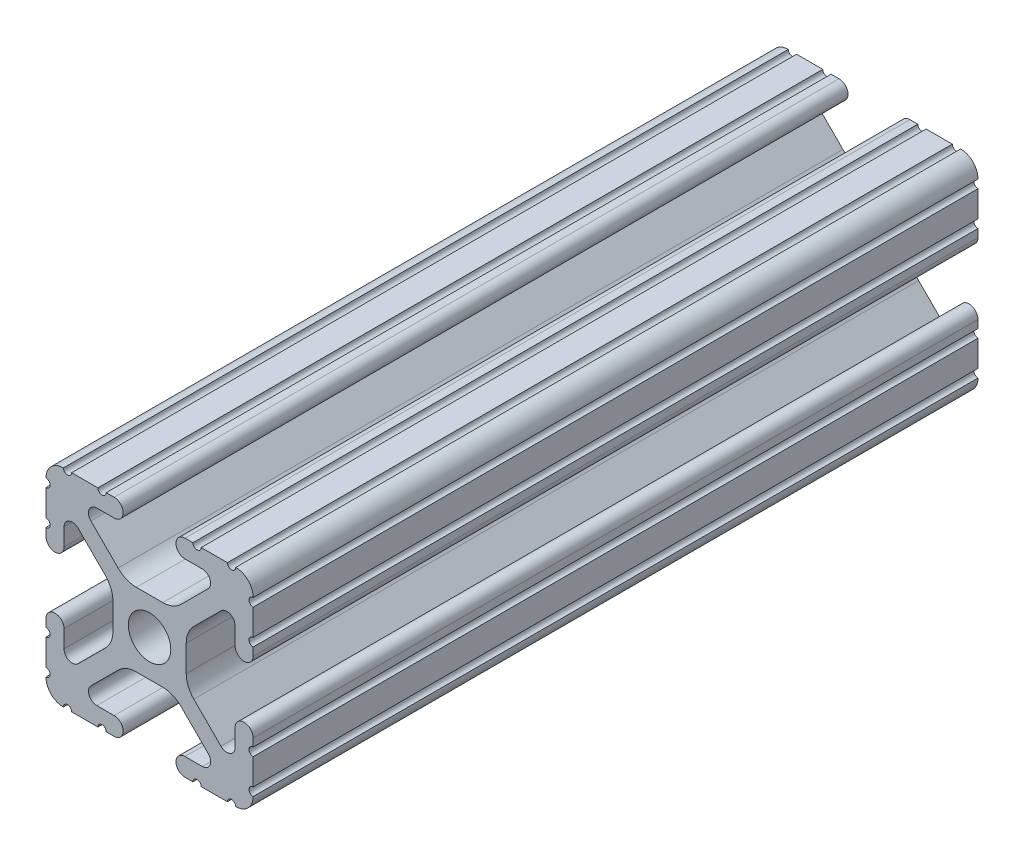
from build123d import *

# Parameters (mm, degrees)
SKETCH1_R           = 2.6035
BOSS_EXTRUDE1_DEPTH = 44.45


with BuildPart() as part:
    # Sketch1 → Boss-Extrude1 (new body, symmetric)
    with BuildSketch(Plane(origin=(0, 0, -450.85), x_dir=(-1, 0, 0), z_dir=(0, 0, -1))):
        with BuildLine():
            Line((12.7, -9.5504), (12.7, -6.3330836))
            ThreePointArc((12.7, -6.3330836), (12.192, -5.8250836), (12.7, -5.3170836))
            Line((12.7, -5.3170836), (12.7, -4.3434))
            ThreePointArc((12.7, -4.3434), (11.5951, -3.2385), (10.4902, -4.3434))
            Line((10.4902, -4.3434), (10.4902, -6.474794456))
            ThreePointArc((10.4902, -6.474794456), (9.863006367, -7.413456061), (8.75577951, -7.193214945))
            Line((8.75577951, -7.193214945), (5.42573597, -3.863171405))
            ThreePointArc((5.42573597, -3.863171405), (4.737482484, -2.833127272), (4.4958, -1.618107374))
            Line((4.4958, -1.618107374), (4.4958, 1.618107374))
            ThreePointArc((4.4958, 1.618107374), (4.737482484, 2.833127272), (5.42573597, 3.863171405))
            Line((5.42573597, 3.863171405), (8.75577951, 7.193214945))
            ThreePointArc((8.75577951, 7.193214945), (9.863006367, 7.413456061), (10.4902, 6.474794456))
            Line((10.4902, 6.474794456), (10.4902, 4.343399971))
            ThreePointArc((10.4902, 4.343399971), (11.5951, 3.238499971), (12.7, 4.343399971))
            Line((12.7, 4.343399971), (12.7, 5.3170836))
            ThreePointArc((12.7, 5.3170836), (12.192, 5.8250836), (12.7, 6.3330836))
            Line((12.7, 6.3330836), (12.7, 9.5504))
            ThreePointArc((12.7, 9.5504), (12.192000006, 10.058323491), (12.699846982, 10.566399977))
            ThreePointArc((12.699846982, 10.566399977), (12.082522516, 12.082522516), (10.566399977, 12.699846982))
            ThreePointArc((10.566399977, 12.699846982), (10.058323491, 12.192000006), (9.5504, 12.7))
            Line((9.5504, 12.7), (6.3330836, 12.7))
            ThreePointArc((6.3330836, 12.7), (5.8250836, 12.192), (5.3170836, 12.7))
            Line((5.3170836, 12.7), (4.3434, 12.7))
            ThreePointArc((4.3434, 12.7), (3.2385, 11.5951), (4.3434, 10.4902))
            Line((4.3434, 10.4902), (6.474794456, 10.4902))
            ThreePointArc((6.474794456, 10.4902), (7.413456061, 9.863006367), (7.193214945, 8.75577951))
            Line((7.193214945, 8.75577951), (3.863171405, 5.42573597))
            ThreePointArc((3.863171405, 5.42573597), (2.833127272, 4.737482484), (1.618107374, 4.4958))
            Line((1.618107374, 4.4958), (-1.618107374, 4.4958))
            ThreePointArc((-1.618107374, 4.4958), (-2.833127272, 4.737482484), (-3.863171405, 5.42573597))
            Line((-3.863171405, 5.42573597), (-7.193214945, 8.75577951))
            ThreePointArc((-7.193214945, 8.75577951), (-7.413456061, 9.863006367), (-6.474794456, 10.4902))
            Line((-6.474794456, 10.4902), (-4.343399971, 10.4902))
            ThreePointArc((-4.343399971, 10.4902), (-3.238499971, 11.5951), (-4.343399971, 12.7))
            Line((-4.343399971, 12.7), (-5.3170836, 12.7))
            ThreePointArc((-5.3170836, 12.7), (-5.8250836, 12.192), (-6.3330836, 12.7))
            Line((-6.3330836, 12.7), (-9.5504, 12.7))
            ThreePointArc((-9.5504, 12.7), (-10.058323491, 12.192000006), (-10.566399977, 12.699846982))
            ThreePointArc((-10.566399977, 12.699846982), (-12.082522516, 12.082522516), (-12.699846982, 10.566399977))
            ThreePointArc((-12.699846982, 10.566399977), (-12.192000006, 10.058323491), (-12.7, 9.5504))
            Line((-12.7, 9.5504), (-12.7, 6.3330836))
            ThreePointArc((-12.7, 6.3330836), (-12.192, 5.8250836), (-12.7, 5.3170836))
            Line((-12.7, 5.3170836), (-12.7, 4.3434))
            ThreePointArc((-12.7, 4.3434), (-11.5951, 3.2385), (-10.4902, 4.3434))
            Line((-10.4902, 4.3434), (-10.4902, 6.474794456))
            ThreePointArc((-10.4902, 6.474794456), (-9.863006367, 7.413456061), (-8.75577951, 7.193214945))
            Line((-8.75577951, 7.193214945), (-5.42573597, 3.863171405))
            ThreePointArc((-5.42573597, 3.863171405), (-4.737482484, 2.833127272), (-4.4958, 1.618107374))
            Line((-4.4958, 1.618107374), (-4.4958, -1.618107374))
            ThreePointArc((-4.4958, -1.618107374), (-4.737482484, -2.833127272), (-5.42573597, -3.863171405))
            Line((-5.42573597, -3.863171405), (-8.75577951, -7.193214945))
            ThreePointArc((-8.75577951, -7.193214945), (-9.863006367, -7.413456061), (-10.4902, -6.474794456))
            Line((-10.4902, -6.474794456), (-10.4902, -4.343399971))
            ThreePointArc((-10.4902, -4.343399971), (-11.5951, -3.238499971), (-12.7, -4.343399971))
            Line((-12.7, -4.343399971), (-12.7, -5.3170836))
            ThreePointArc((-12.7, -5.3170836), (-12.192, -5.8250836), (-12.7, -6.3330836))
            Line((-12.7, -6.3330836), (-12.7, -9.5504))
            ThreePointArc((-12.7, -9.5504), (-12.192000006, -10.058323491), (-12.699846982, -10.566399977))
            ThreePointArc((-12.699846982, -10.566399977), (-12.082522516, -12.082522516), (-10.566399977, -12.699846982))
            ThreePointArc((-10.566399977, -12.699846982), (-10.058323491, -12.192000006), (-9.5504, -12.7))
            Line((-9.5504, -12.7), (-6.3330836, -12.7))
            ThreePointArc((-6.3330836, -12.7), (-5.8250836, -12.192), (-5.3170836, -12.7))
            Line((-5.3170836, -12.7), (-4.3434, -12.7))
            ThreePointArc((-4.3434, -12.7), (-3.2385, -11.5951), (-4.3434, -10.4902))
            Line((-4.3434, -10.4902), (-6.474794456, -10.4902))
            ThreePointArc((-6.474794456, -10.4902), (-7.413456061, -9.863006367), (-7.193214945, -8.75577951))
            Line((-7.193214945, -8.75577951), (-3.863171405, -5.42573597))
            ThreePointArc((-3.863171405, -5.42573597), (-2.833127272, -4.737482484), (-1.618107374, -4.4958))
            Line((-1.618107374, -4.4958), (1.618107374, -4.4958))
            ThreePointArc((1.618107374, -4.4958), (2.833127272, -4.737482484), (3.863171405, -5.42573597))
            Line((3.863171405, -5.42573597), (7.193214945, -8.75577951))
            ThreePointArc((7.193214945, -8.75577951), (7.413456061, -9.863006367), (6.474794456, -10.4902))
            Line((6.474794456, -10.4902), (4.343399971, -10.4902))
            ThreePointArc((4.343399971, -10.4902), (3.238499971, -11.5951), (4.343399971, -12.7))
            Line((4.343399971, -12.7), (5.3170836, -12.7))
            ThreePointArc((5.3170836, -12.7), (5.8250836, -12.192), (6.3330836, -12.7))
            Line((6.3330836, -12.7), (9.5504, -12.7))
            ThreePointArc((9.5504, -12.7), (10.058323491, -12.192000006), (10.566399977, -12.699846982))
            ThreePointArc((10.566399977, -12.699846982), (12.082522516, -12.082522516), (12.699846982, -10.566399977))
            ThreePointArc((12.699846982, -10.566399977), (12.192000006, -10.058323491), (12.7, -9.5504))
        make_face()
        Circle(SKETCH1_R, mode=Mode.SUBTRACT)
    extrude(amount=BOSS_EXTRUDE1_DEPTH, both=True)


solid = part.part
